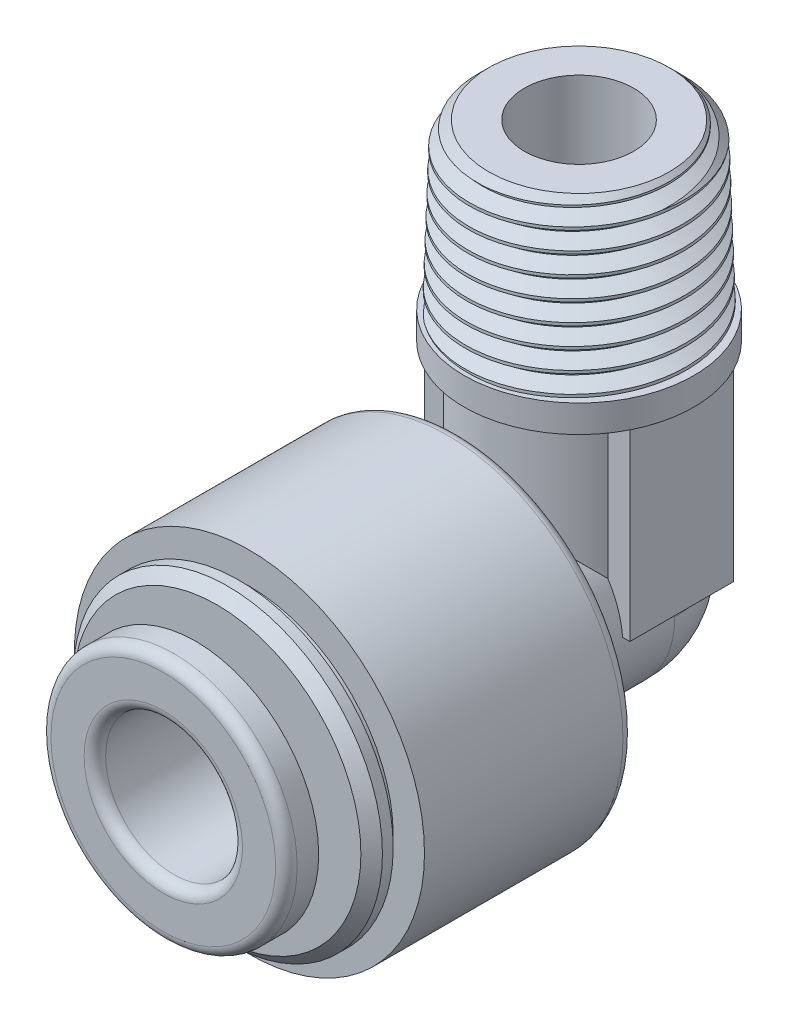
from build123d import *

# Parameters (mm, degrees)
SKETCH4_R              = 5.1435
BOSS_EXTRUDE2_DEPTH    = 7.62
BOSS_EXTRUDE2_TAPER    = 1.783333333
CUT_SWEEP1_PITCH       = 0.941196605
CUT_SWEEP1_HEIGHT      = 8.560740741
CUT_SWEEP1_RADIUS      = 4.90625059
CUT_SWEEP1_START_ANGLE = 180
SKETCH7_OUTSIDE_W      = 61.67
SKETCH7_OUTSIDE_H      = 70.052
SKETCH7_OUTSIDE_R      = 4.193383382
CUT_EXTRUDE1_DEPTH     = 17.78
CUT_EXTRUDE1_DRAFT     = -45
BOSS_EXTRUDE3_DEPTH    = 9.779
FILLET1_R              = 0.5
SKETCH9_R              = 2.54
CUT_EXTRUDE3_DEPTH     = 17.78


with BuildPart() as part:
    # Sketch2 → Revolve1 (revolve)
    with BuildSketch(Plane(origin=(0, 0, 0), x_dir=(0, 0, -1), z_dir=(1, 0, 0)), mode=Mode.PRIVATE) as revolve1_sk:
        with BuildLine():
            Line((-19.304, 0), (4.445, 0))
            ThreePointArc((4.445, 0), (3.143089642, 3.143089642), (0, 4.445))
            Line((0, 4.445), (-5.338, 4.445))
            ThreePointArc((-5.338, 4.445), (-5.514776695, 4.518223305), (-5.588, 4.695))
            Line((-5.588, 4.695), (-5.588, 7.628))
            ThreePointArc((-5.588, 7.628), (-5.734446609, 7.981553391), (-6.088, 8.128))
            Line((-6.088, 8.128), (-15.304, 8.128))
            Line((-15.304, 8.128), (-15.304, 6.6755))
            Line((-15.304, 6.6755), (-15.804, 6.6755))
            Line((-15.804, 6.6755), (-15.804, 7.1755))
            Line((-15.804, 7.1755), (-16.304, 7.1755))
            Line((-16.304, 7.1755), (-16.804, 6.6755))
            Line((-16.804, 6.6755), (-16.804, 3.81))
            Line((-16.804, 3.81), (-17.804, 3.81))
            Line((-17.804, 3.81), (-17.804, 5.715))
            Line((-17.804, 5.715), (-19.304, 5.715))
            Line((-19.304, 5.715), (-19.304, 0))
        make_face()
    revolve(revolve1_sk.sketch.rotate(Axis((0, 0, 19.304), (0, 0, -1)), 90), axis=Axis((0, 0, 19.304), (0, 0, -1)))

    # Sketch3 → Revolve2 (revolve)
    with BuildSketch(Plane(origin=(0, 0, 0), x_dir=(0, 0, -1), z_dir=(1, 0, 0))):
        with BuildLine():
            Line((0, -4.445), (0, 10.16))
            Line((0, 10.16), (5.334, 10.16))
            Line((5.334, 10.16), (5.334, 8.89))
            Line((5.334, 8.89), (4.445, 8.376735611))
            Line((4.445, 8.376735611), (4.445, 0))
            ThreePointArc((4.445, 0), (3.143089642, -3.143089642), (0, -4.445))
        make_face()
    revolve(axis=Axis((0, -4.445, 0), (0, 1, 0)))



with BuildPart() as body_2:
    # Sketch4 → Boss-Extrude2 (new body)
    with BuildSketch(Plane(origin=(0, 10.16, 0), x_dir=(-1, 0, 0), z_dir=(0, 1, 0))):
        Circle(SKETCH4_R)
    extrude(amount=BOSS_EXTRUDE2_DEPTH, taper=BOSS_EXTRUDE2_TAPER)

    # Cut-Sweep1: sweep along a helix
    with BuildLine() as cut_sweep1_path:
        # a taper helix: rise per turn along the axis 0.940740741, along the cone's slant (build123d's pitch) 0.941196605
        add(Helix(CUT_SWEEP1_PITCH, CUT_SWEEP1_HEIGHT, CUT_SWEEP1_RADIUS, center=(0, 17.78, 0), direction=(0, -1, 0), cone_angle=1.783333333, mode=Mode.PRIVATE).rotate(Axis((0, 17.78, 0), (0, -1, 0)), CUT_SWEEP1_START_ANGLE))
    # Sketch6 → Cut-Sweep1 (sweep, cut)
    with BuildSketch(Plane(origin=(0, 0, 0), x_dir=(0, 0, -1), z_dir=(1, 0, 0))):
        Polygon((-4.295221555, 18.132777778), (-4.295221555, 18.25037037), (-4.957169676, 18.632546296), (-4.957169676, 17.750601852), align=None)
    sweep(path=cut_sweep1_path.line, is_frenet=True, mode=Mode.SUBTRACT)


with BuildPart() as cut_extrude1_tool:
    # Sketch7 outside → Cut-Extrude1 (with draft: the straight prism first)
    with BuildSketch(Plane(origin=(0, 17.78, 0), x_dir=(-1, 0, 0), z_dir=(0, 1, 0))):
        with Locations((0, 6.985)):
            Rectangle(SKETCH7_OUTSIDE_W, SKETCH7_OUTSIDE_H)
        Circle(SKETCH7_OUTSIDE_R, mode=Mode.SUBTRACT)
    extrude(amount=-CUT_EXTRUDE1_DEPTH)
    # Cut-Extrude1: the draft: its side faces are tilted about the plane it starts from
    cut_extrude1_sides = [cut_extrude1_tool.faces().sort_by_distance(p)[0] for p in [
        (0, 8.89, -28.041),
        (-30.835, 8.89, 6.985),
        (0, 8.89, 42.011),
        (30.835, 8.89, 6.985),
        (4.193383382, 8.89, 0),
    ]]
    draft(cut_extrude1_sides, Plane(origin=(0, 17.78, 0), x_dir=(-1, 0, 0), z_dir=(0, 1, 0)), CUT_EXTRUDE1_DRAFT)


with BuildPart() as body_2_1:
    add(body_2.part)

    # Cut-Extrude1: cut by cut_extrude1_tool
    add(cut_extrude1_tool.part, mode=Mode.SUBTRACT)


with BuildPart() as part_1:
    add(part.part)

    add(body_2_1.part)  # Boss-Extrude3 merges body 2
    # Sketch10 → Boss-Extrude3 (add)
    with BuildSketch(Plane(origin=(0, 10.16, 0), x_dir=(1, 0, 0), z_dir=(0, 1, 0))):
        with BuildLine():
            Line((0.8255, 2.402113601), (4.7625, 2.402113601))
            Line((4.7625, 2.402113601), (4.7625, -2.402113601))
            Line((4.7625, -2.402113601), (0.8255, -2.402113601))
            ThreePointArc((0.8255, -2.402113601), (2.54, 0), (0.8255, 2.402113601))
        make_face()
        with BuildLine():
            Line((-4.7625, -2.402113601), (-0.8255, -2.402113601))
            ThreePointArc((-0.8255, -2.402113601), (-2.54, 0), (-0.8255, 2.402113601))
            Line((-0.8255, 2.402113601), (-4.7625, 2.402113601))
            Line((-4.7625, 2.402113601), (-4.7625, -2.402113601))
        make_face()
    extrude(amount=-BOSS_EXTRUDE3_DEPTH)

    # Sketch8 → Cut-Revolve2 (revolve, cut)
    with BuildSketch(Plane(origin=(0, 0, 0), x_dir=(0, 0, -1), z_dir=(1, 0, 0))):
        with BuildLine():
            Line((-19.304, 3.175), (-3.556, 3.175))
            Line((-3.556, 3.175), (-3.556, 2.54))
            Line((-3.556, 2.54), (0, 2.54))
            ThreePointArc((0, 2.54), (1.796051224, 1.796051224), (2.54, 0))
            Line((2.54, 0), (-19.304, 0))
            Line((-19.304, 0), (-19.304, 3.175))
        make_face()
    revolve(axis=Axis((0, 0, -2.54), (0, 0, 1)), mode=Mode.SUBTRACT)

    # Fillet1
    fillet1_edges = [part_1.edges().sort_by_distance(p)[0] for p in [
        (0, -3.175, 19.304),
        (-5.715, 0, 19.304),
    ]]
    fillet(fillet1_edges, radius=FILLET1_R)

    # Sketch9 → Cut-Extrude3 (cut)
    with BuildSketch(Plane(origin=(0, 17.78, 0), x_dir=(1, 0, 0), z_dir=(0, 1, 0))):
        with Locations(Location((0, 0, 0), (0, 0, 270))):
            Circle(SKETCH9_R)
    extrude(amount=-CUT_EXTRUDE3_DEPTH, mode=Mode.SUBTRACT)


solid = part_1.part
